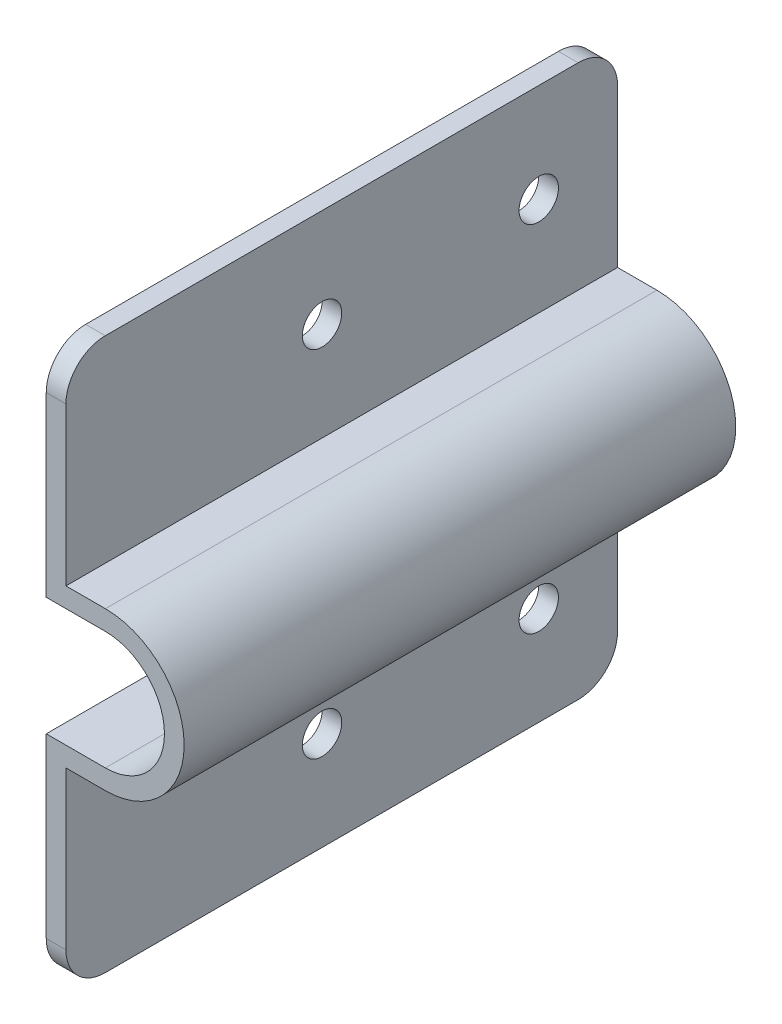
from build123d import *

# Parameters (mm, degrees)
BOSS_EXTRUDE1_DEPTH = 88.9
SKETCH2_R           = 3.175
CUT_EXTRUDE1_DEPTH  = 4.175
FILLET1_R           = 6.35


with BuildPart() as part:
    # Sketch1 → Boss-Extrude1 (new body)
    with BuildSketch(Plane.XY):
        with BuildLine():
            Line((13.335, 323.089397322), (10.16, 323.089397322))
            Line((10.16, 323.089397322), (10.16, 288.164397322))
            Line((10.16, 288.164397322), (19.685, 288.164397322))
            ThreePointArc((19.685, 288.164397322), (29.21, 278.639397322), (19.685, 269.114397322))
            Line((19.685, 269.114397322), (10.16, 269.114397322))
            Line((10.16, 269.114397322), (10.16, 234.189397322))
            Line((10.16, 234.189397322), (13.335, 234.189397322))
            Line((13.335, 234.189397322), (13.335, 265.939397322))
            Line((13.335, 265.939397322), (19.685, 265.939397322))
            ThreePointArc((19.685, 265.939397322), (32.385, 278.639397322), (19.685, 291.339397322))
            Line((19.685, 291.339397322), (13.335, 291.339397322))
            Line((13.335, 291.339397322), (13.335, 323.089397322))
        make_face()
    extrude(amount=-BOSS_EXTRUDE1_DEPTH)

    # Sketch2 → Cut-Extrude1 (cut, through all)
    with BuildSketch(Plane(origin=(13.335, 0, 0), x_dir=(0, 0, -1), z_dir=(1, 0, 0))):
        with Locations((41.275, 250.064397322)):
            Circle(SKETCH2_R)
        with Locations((76.2, 250.064397322)):
            Circle(SKETCH2_R)
        with Locations((76.2, 307.214397322)):
            Circle(SKETCH2_R)
        with Locations((41.275, 307.214397322)):
            Circle(SKETCH2_R)
    extrude(amount=-CUT_EXTRUDE1_DEPTH, mode=Mode.SUBTRACT)

    # Fillet1
    fillet1_edges = [part.edges().sort_by_distance(p)[0] for p in [
        (11.7475, 323.089397322, 0),
        (11.7475, 234.189397322, 0),
        (11.7475, 234.189397322, -88.9),
        (11.7475, 323.089397322, -88.9),
    ]]
    fillet(fillet1_edges, radius=FILLET1_R)


solid = part.part
